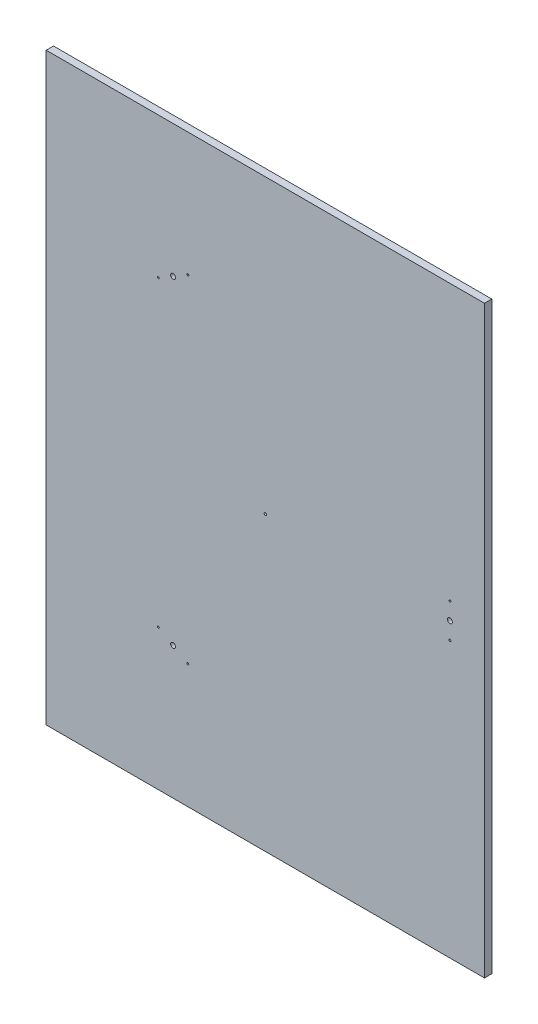
from build123d import *

# Parameters (mm, degrees)
ESQUISSE1_W        = 900
ESQUISSE1_H        = 1200
ESQUISSE1_R        = 5
ESQUISSE1_R_2      = 2
ESQUISSE1_R_3      = 2.5
BOSS_EXTRU_1_DEPTH = 15


with BuildPart() as part:
    # Esquisse1 → Boss.-Extru.1 (new body)
    with BuildSketch(Plane.XY):
        Rectangle(ESQUISSE1_W, ESQUISSE1_H)
        with Locations((379, 0)):
            Circle(ESQUISSE1_R, mode=Mode.SUBTRACT)
        with Locations((379, 35)):
            Circle(ESQUISSE1_R_2, mode=Mode.SUBTRACT)
        with Locations((379, -35)):
            Circle(ESQUISSE1_R_2, mode=Mode.SUBTRACT)
        with Locations((-189.5, -328.223628034)):
            Circle(ESQUISSE1_R, mode=Mode.SUBTRACT)
        with Locations((-159.189110868, -345.723628034)):
            Circle(ESQUISSE1_R_2, mode=Mode.SUBTRACT)
        with Locations((-219.810889132, -310.723628034)):
            Circle(ESQUISSE1_R_2, mode=Mode.SUBTRACT)
        with Locations((-189.5, 328.223628034)):
            Circle(ESQUISSE1_R, mode=Mode.SUBTRACT)
        with Locations((-219.810889132, 310.723628034)):
            Circle(ESQUISSE1_R_2, mode=Mode.SUBTRACT)
        with Locations((-159.189110868, 345.723628034)):
            Circle(ESQUISSE1_R_2, mode=Mode.SUBTRACT)
        Circle(ESQUISSE1_R_3, mode=Mode.SUBTRACT)
    extrude(amount=BOSS_EXTRU_1_DEPTH)


solid = part.part
